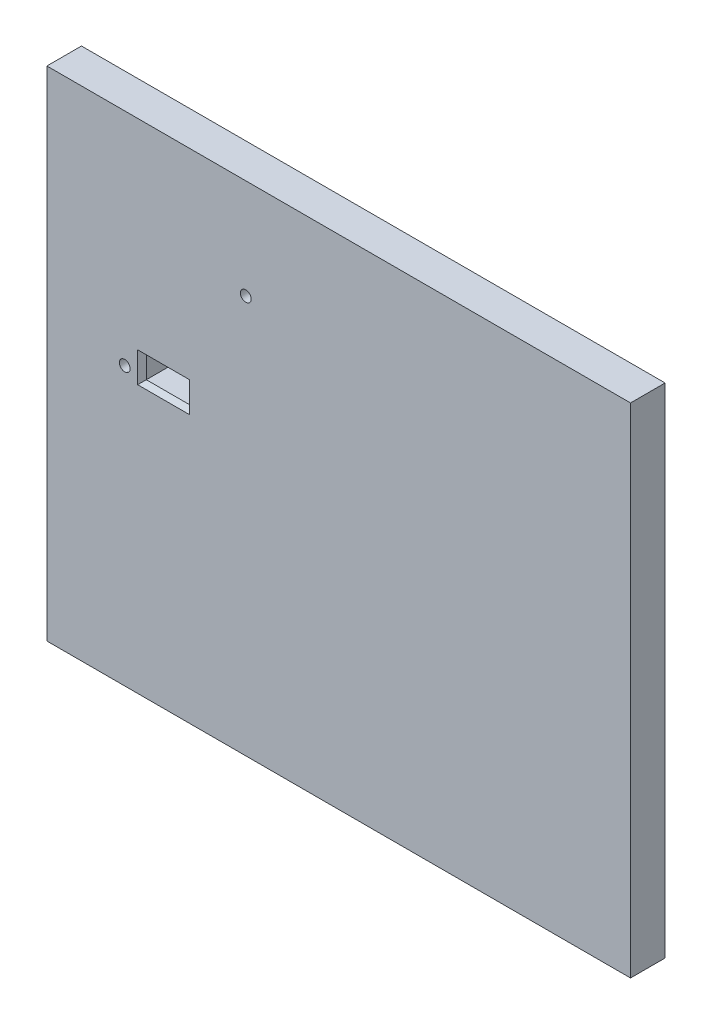
from build123d import *

# Parameters (mm, degrees)
BOSS_EXTRUDE1_START = 65
SKETCH1_W           = 135
SKETCH1_H           = 115.198794821
BOSS_EXTRUDE1_DEPTH = 8
SKETCH2_W           = 10
SKETCH2_H           = 5
CUT_EXTRUDE1_DEPTH  = 9
SKETCH3_R           = 1.25
CUT_EXTRUDE2_DEPTH  = 9
CHAMFER2_SIZE       = 1


with BuildPart() as part:
    # Sketch1 → Boss-Extrude1 (new body)
    with BuildSketch(Plane.XY.offset(BOSS_EXTRUDE1_START)):
        with Locations((0, 37.599397411)):
            Rectangle(SKETCH1_W, SKETCH1_H)
    extrude(amount=BOSS_EXTRUDE1_DEPTH)

    # Sketch2 → Cut-Extrude1 (cut, through all)
    with BuildSketch(Plane.XY.offset(73)):
        with Locations((-40.5, 45.346)):
            Rectangle(SKETCH2_W, SKETCH2_H)
    extrude(amount=-CUT_EXTRUDE1_DEPTH, mode=Mode.SUBTRACT)

    # Sketch3 → Cut-Extrude2 (cut, through all)
    with BuildSketch(Plane.XY.offset(73)):
        with Locations((-21.5, 72.116)):
            Circle(SKETCH3_R)
        with Locations((-49.5, 44.176)):
            Circle(SKETCH3_R)
    extrude(amount=-CUT_EXTRUDE2_DEPTH, mode=Mode.SUBTRACT)

    # Chamfer2
    chamfer2_edges = [part.edges().sort_by_distance(p)[0] for p in [
        (-40.5, 47.846, 73),
        (-45.5, 45.346, 73),
        (-40.5, 42.846, 73),
        (-35.5, 45.346, 73),
    ]]
    chamfer(chamfer2_edges, length=CHAMFER2_SIZE)


solid = part.part
